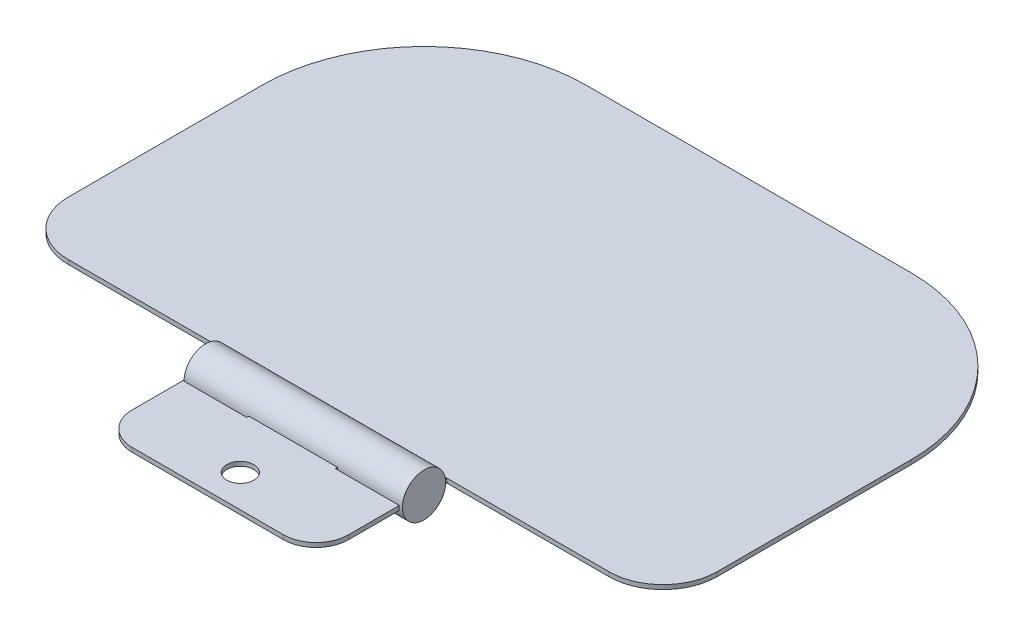
from build123d import *
from build123d.topology import SkipClean

# Parameters (mm, degrees)
EXTRUDE_1_DEPTH      = 0.2
EXTRUDE_1_DEPTH_BACK = 0.2
SKETCH_2_R           = 1.25
EXTRUDE_3_DEPTH      = 0.1
EXTRUDE_3_DEPTH_BACK = 20.1
SKETCH_4_R           = 2
SKETCH_6_R           = 2.2
SKETCH_6_R_2         = 2
CUT_EXTRUDE_2_DEPTH  = 6
CUT_EXTRUDE_START    = -6
SKETCH_7_R           = 2.2
SKETCH_7_R_2         = 2
CUT_EXTRUDE_3_DEPTH  = 6


with BuildPart() as part:
    # 草图2 → 凸台-拉伸1 (new, two sides: drawn at the far end of the back side and taken through both)
    with BuildSketch(Plane(origin=(0, 0, 0), x_dir=(1, 0, 0), z_dir=(0, 1, 0)).offset(-EXTRUDE_1_DEPTH_BACK)):
        with BuildLine():
            Line((-23.791283512, 37.576059538), (-8.791283512, 37.576059538))
            Line((-8.791283512, 37.576059538), (-8.791283512, 28.485605042))
            ThreePointArc((-8.791283512, 28.485605042), (-7.912603856, 26.364284699), (-5.791283512, 25.485605042))
            Line((-5.791283512, 25.485605042), (8.208716488, 25.485605042))
            ThreePointArc((8.208716488, 25.485605042), (10.330036831, 26.364284699), (11.208716488, 28.485605042))
            Line((11.208716488, 28.485605042), (11.208716488, 37.576059538))
            Line((11.208716488, 37.576059538), (26.208716488, 37.576059538))
            ThreePointArc((26.208716488, 37.576059538), (29.744250394, 39.040525632), (31.208716488, 42.576059538))
            Line((31.208716488, 42.576059538), (31.208716488, 60.485605042))
            ThreePointArc((31.208716488, 60.485605042), (26.815318205, 71.09220676), (16.208716488, 75.485605042))
            Line((16.208716488, 75.485605042), (-13.791283512, 75.485605042))
            ThreePointArc((-13.791283512, 75.485605042), (-24.399223726, 71.093545256), (-28.791283512, 60.485605042))
            Line((-28.791283512, 60.485605042), (-28.791283512, 42.576059538))
            ThreePointArc((-28.791283512, 42.576059538), (-27.326817418, 39.040525632), (-23.791283512, 37.576059538))
        make_face()
        with Locations((1.208716488, 28.485605042)):
            Circle(SKETCH_2_R, mode=Mode.SUBTRACT)
    extrude(amount=EXTRUDE_1_DEPTH + EXTRUDE_1_DEPTH_BACK)

    # 草图4 → 凸台-拉伸3 (add, two sides: drawn at the far end of the back side and taken through both)
    with BuildSketch(Plane(origin=(11.208716488, 0, 0), x_dir=(0, 0, -1), z_dir=(1, 0, 0)).offset(-EXTRUDE_3_DEPTH_BACK)):
        with Locations((35.376059538, 0)):
            Circle(SKETCH_4_R)
    extrude(amount=EXTRUDE_3_DEPTH + EXTRUDE_3_DEPTH_BACK)

    # 草图6 → 切除-拉伸2 (cut)
    with SkipClean():  # the faces are left unmerged after this step: merging them gives an invalid solid
        with BuildSketch(Plane.ZY.offset(8.891283512)):
            with Locations((-35.376059538, 0)):
                Circle(SKETCH_6_R)
            with Locations((-35.376059538, 0)):
                Circle(SKETCH_6_R_2, mode=Mode.SUBTRACT)
        extrude(amount=-CUT_EXTRUDE_2_DEPTH, mode=Mode.SUBTRACT)
    add(part.part.scale(1), mode=Mode.REPLACE)  # the faces are merged on a copy

    # 草图7 → 切除-拉伸3 (cut)
    with BuildSketch(Plane(origin=(11.308716488, 0, 0), x_dir=(0, 0, -1), z_dir=(1, 0, 0)).offset(CUT_EXTRUDE_START)):
        with Locations((35.376059538, 0)):
            Circle(SKETCH_7_R)
        with Locations((35.376059538, 0)):
            Circle(SKETCH_7_R_2, mode=Mode.SUBTRACT)
    extrude(amount=CUT_EXTRUDE_3_DEPTH, mode=Mode.SUBTRACT)


solid = part.part
